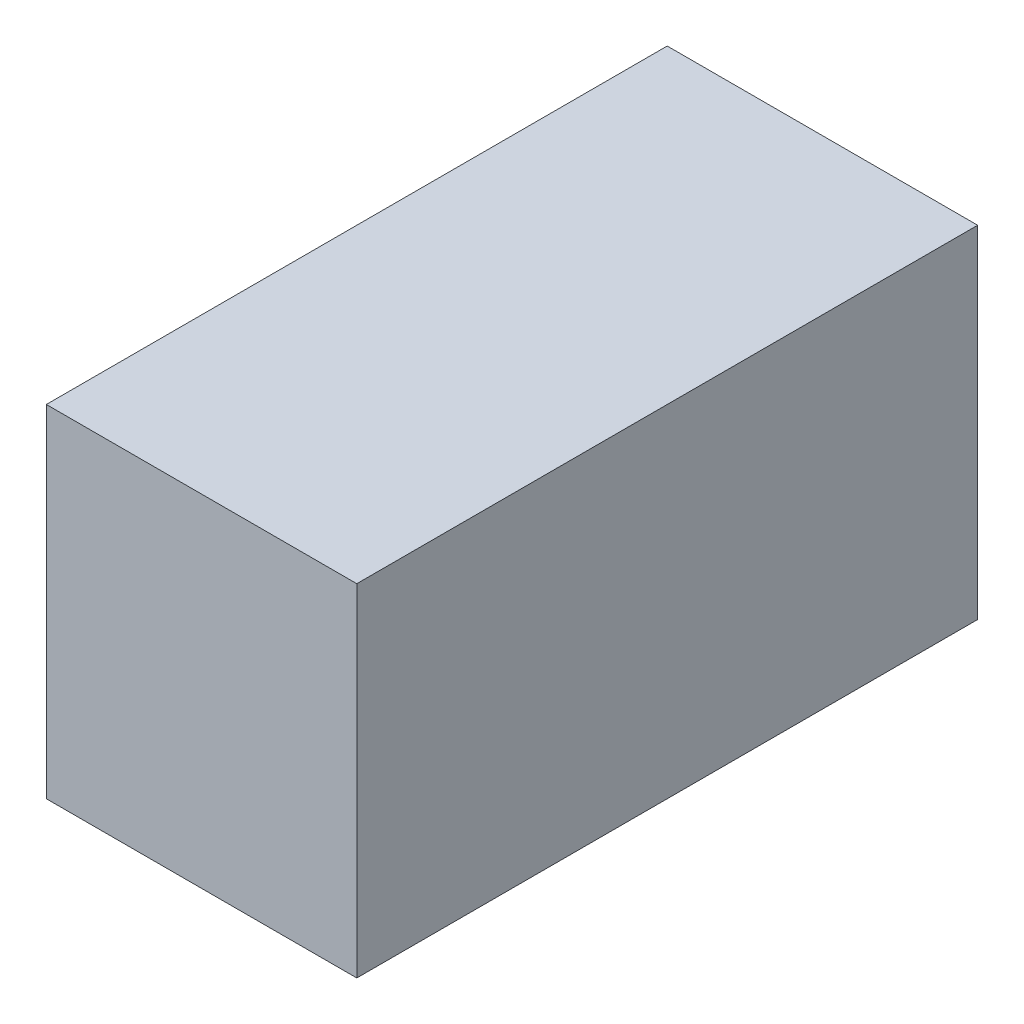
from build123d import *

# Parameters (mm, degrees)
SKETCH1_W           = 0.5
SKETCH1_H           = 1
BOSS_EXTRUDE2_DEPTH = 0.55


with BuildPart() as part:
    # Sketch1 → Boss-Extrude2 (new body)
    with BuildSketch(Plane(origin=(0, 0, 0), x_dir=(1, 0, 0), z_dir=(0, 1, 0))):
        with Locations((0.25, 0.5)):
            Rectangle(SKETCH1_W, SKETCH1_H)
    extrude(amount=BOSS_EXTRUDE2_DEPTH)


solid = part.part
